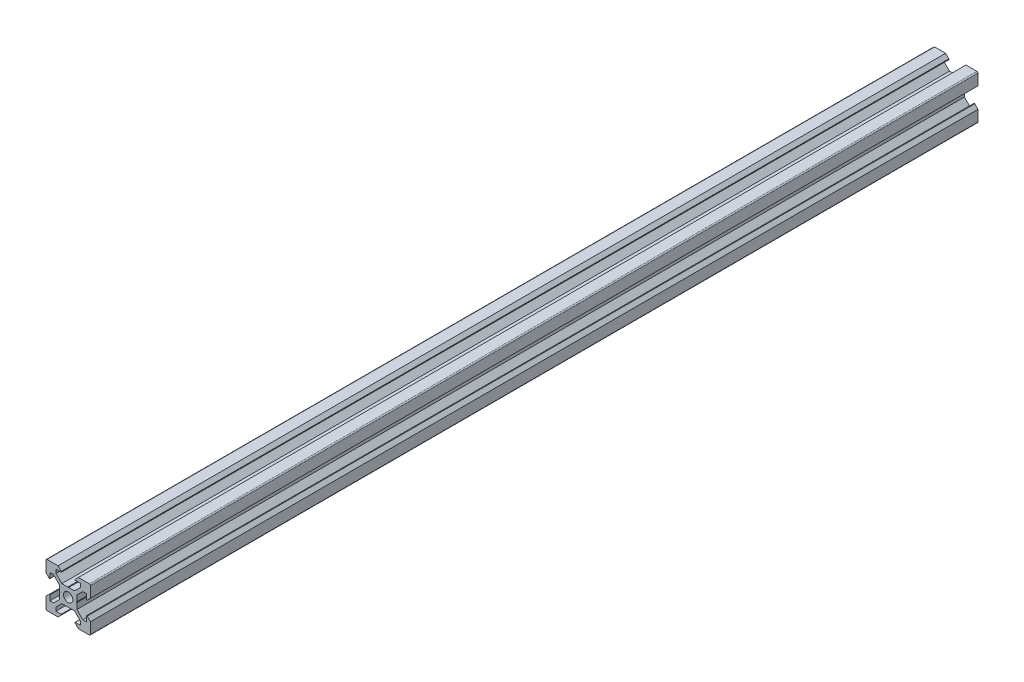
from build123d import *

# Parameters (mm, degrees)
SKETCH1_R           = 2.1
BOSS_EXTRUDE1_DEPTH = 400


with BuildPart() as part:
    # Sketch1 → Boss-Extrude1 (new body)
    with BuildSketch(Plane.XY):
        with BuildLine():
            Line((4.58, -10), (9.5, -10))
            ThreePointArc((9.5, -10), (9.853553391, -9.853553391), (10, -9.5))
            Line((10, -9.5), (10, -4.58))
            Line((10, -4.58), (8.545, -3.125))
            Line((8.545, -3.125), (8.2, -3.125))
            Line((8.2, -3.125), (8.2, -5.5))
            Line((8.2, -5.5), (6.560660172, -5.5))
            Line((6.560660172, -5.5), (3.9, -2.839339828))
            Line((3.9, -2.839339828), (3.9, -0.21))
            Line((3.9, -0.21), (3.69, 0))
            Line((3.69, 0), (3.9, 0.21))
            Line((3.9, 0.21), (3.9, 2.839339828))
            Line((3.9, 2.839339828), (6.560660172, 5.5))
            Line((6.560660172, 5.5), (8.2, 5.5))
            Line((8.2, 5.5), (8.2, 3.125))
            Line((8.2, 3.125), (8.545, 3.125))
            Line((8.545, 3.125), (10, 4.58))
            Line((10, 4.58), (10, 9.5))
            ThreePointArc((10, 9.5), (9.853553391, 9.853553391), (9.5, 10))
            Line((9.5, 10), (4.58, 10))
            Line((4.58, 10), (3.125, 8.545))
            Line((3.125, 8.545), (3.125, 8.2))
            Line((3.125, 8.2), (5.5, 8.2))
            Line((5.5, 8.2), (5.5, 6.560660172))
            Line((5.5, 6.560660172), (2.839339828, 3.9))
            Line((2.839339828, 3.9), (0.21, 3.9))
            Line((0.21, 3.9), (0, 3.69))
            Line((0, 3.69), (-0.21, 3.9))
            Line((-0.21, 3.9), (-2.839339828, 3.9))
            Line((-2.839339828, 3.9), (-5.5, 6.560660172))
            Line((-5.5, 6.560660172), (-5.5, 8.2))
            Line((-5.5, 8.2), (-3.125, 8.2))
            Line((-3.125, 8.2), (-3.125, 8.545))
            Line((-3.125, 8.545), (-4.58, 10))
            Line((-4.58, 10), (-9.5, 10))
            ThreePointArc((-9.5, 10), (-9.853553391, 9.853553391), (-10, 9.5))
            Line((-10, 9.5), (-10, 4.58))
            Line((-10, 4.58), (-8.545, 3.125))
            Line((-8.545, 3.125), (-8.2, 3.125))
            Line((-8.2, 3.125), (-8.2, 5.5))
            Line((-8.2, 5.5), (-6.560660172, 5.5))
            Line((-6.560660172, 5.5), (-3.9, 2.839339828))
            Line((-3.9, 2.839339828), (-3.9, 0.21))
            Line((-3.9, 0.21), (-3.69, 0))
            Line((-3.69, 0), (-3.9, -0.21))
            Line((-3.9, -0.21), (-3.9, -2.839339828))
            Line((-3.9, -2.839339828), (-6.560660172, -5.5))
            Line((-6.560660172, -5.5), (-8.2, -5.5))
            Line((-8.2, -5.5), (-8.2, -3.125))
            Line((-8.2, -3.125), (-8.545, -3.125))
            Line((-8.545, -3.125), (-10, -4.58))
            Line((-10, -4.58), (-10, -9.5))
            ThreePointArc((-10, -9.5), (-9.853553391, -9.853553391), (-9.5, -10))
            Line((-9.5, -10), (-4.58, -10))
            Line((-4.58, -10), (-3.125, -8.545))
            Line((-3.125, -8.545), (-3.125, -8.2))
            Line((-3.125, -8.2), (-5.5, -8.2))
            Line((-5.5, -8.2), (-5.5, -6.560660172))
            Line((-5.5, -6.560660172), (-2.839339828, -3.9))
            Line((-2.839339828, -3.9), (-0.21, -3.9))
            Line((-0.21, -3.9), (0, -3.69))
            Line((0, -3.69), (0.21, -3.9))
            Line((0.21, -3.9), (2.839339828, -3.9))
            Line((2.839339828, -3.9), (5.5, -6.560660172))
            Line((5.5, -6.560660172), (5.5, -8.2))
            Line((5.5, -8.2), (3.125, -8.2))
            Line((3.125, -8.2), (3.125, -8.545))
            Line((3.125, -8.545), (4.58, -10))
        make_face()
        Circle(SKETCH1_R, mode=Mode.SUBTRACT)
    extrude(amount=BOSS_EXTRUDE1_DEPTH)


solid = part.part
